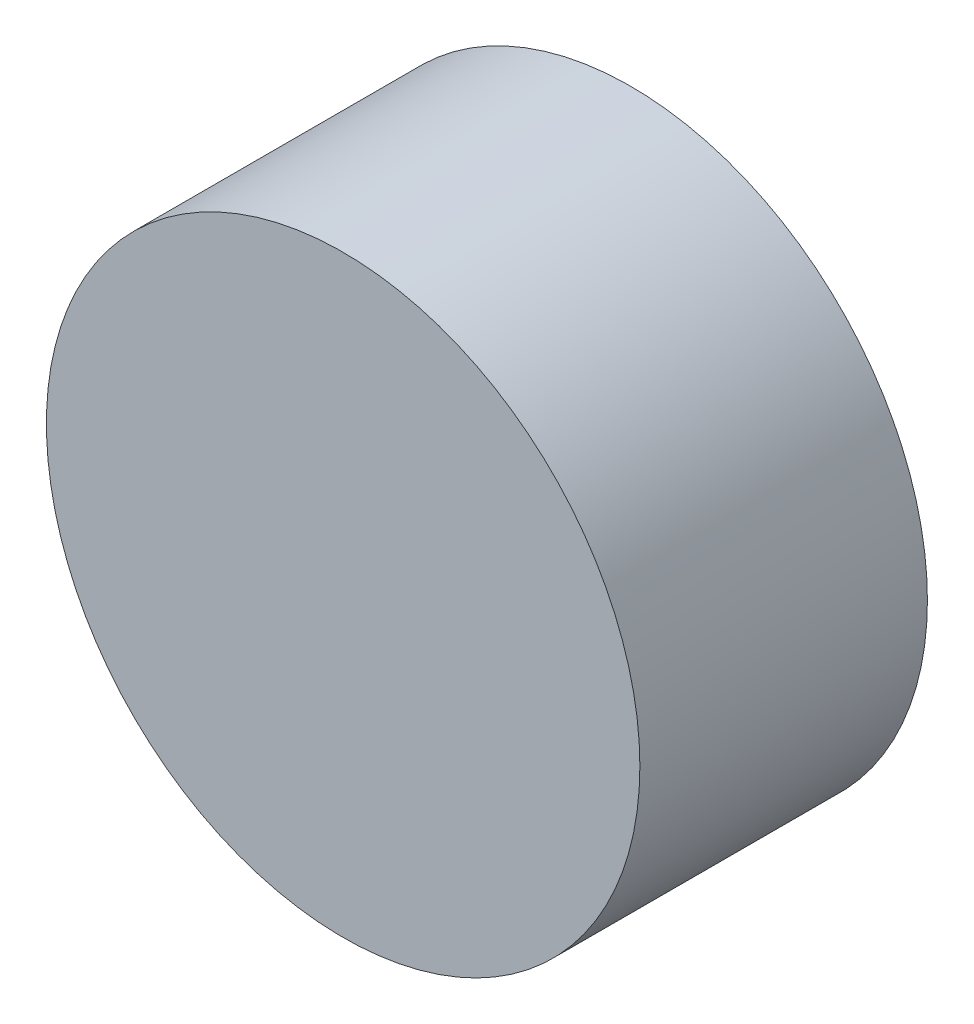
from build123d import *

# Parameters (mm, degrees)
SKETCH1_R           = 3.2766
BOSS_EXTRUDE1_DEPTH = 3.175


with BuildPart() as part:
    # Sketch1 → Boss-Extrude1 (new body)
    with BuildSketch(Plane.XY):
        Circle(SKETCH1_R)
    extrude(amount=BOSS_EXTRUDE1_DEPTH)


solid = part.part
